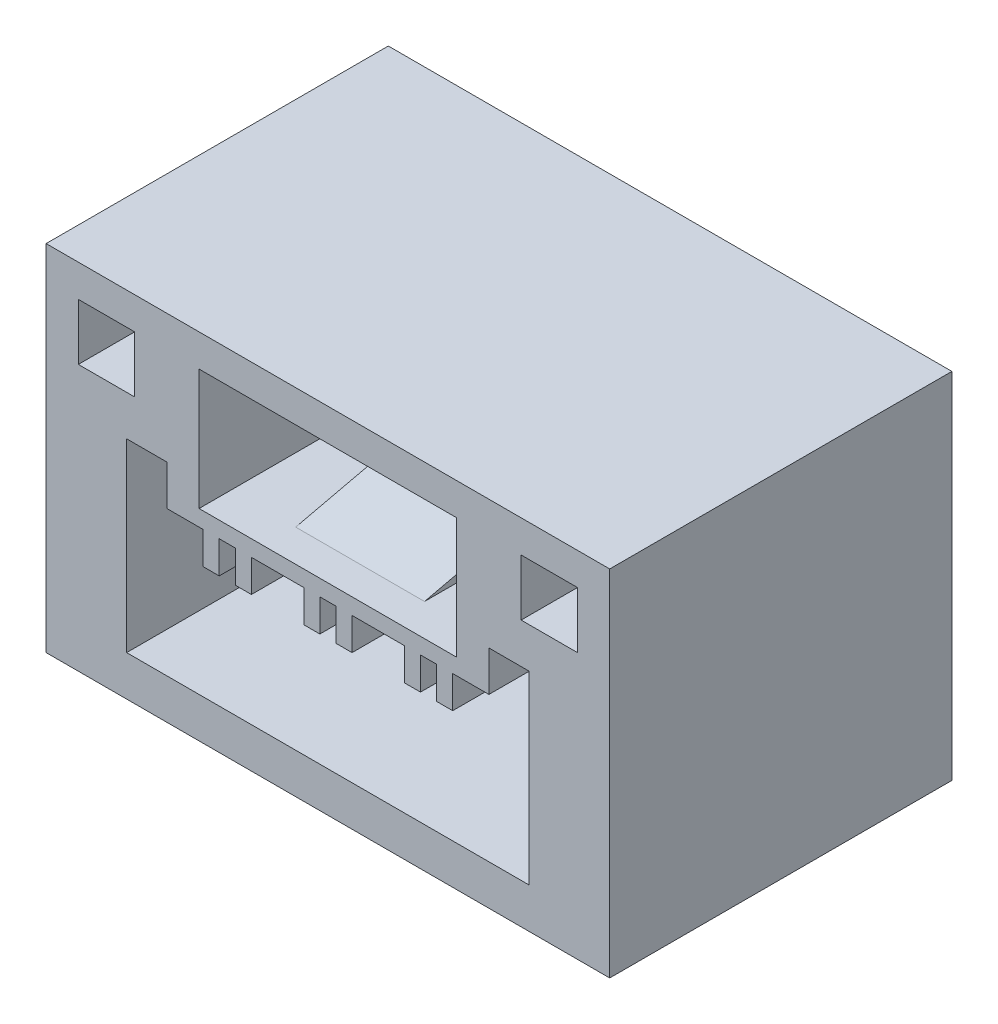
from build123d import *

# Parameters (mm, degrees)
SKETCH1_W                = 7
SKETCH1_H                = 4.4
SKETCH1_W_2              = 0.7
SKETCH1_H_2              = 0.7
SKETCH1_W_3              = 3.2
SKETCH1_H_3              = 1.5
BOSS_EXTRUDE1_DEPTH      = 4.25
SKETCH1_2_W              = 0.7
SKETCH1_2_H              = 0.7
BOSS_EXTRUDE2_DEPTH      = 1
BOSS_EXTRUDE3_START      = 4.25
SKETCH3_W                = 0.2
SKETCH3_H                = 0.4
BOSS_EXTRUDE3_DEPTH      = 3.25
LPATTERN1_COUNT          = 3
LPATTERN1_PITCH          = 1.25
BOSS_EXTRUDE4_DEPTH      = 0.8
BOSS_EXTRUDE4_DEPTH_BACK = 0.8


with BuildPart() as part:
    # Sketch1 → Boss-Extrude1 (new body)
    with BuildSketch(Plane.XY):
        Rectangle(SKETCH1_W, SKETCH1_H)
        Polygon((-2.5, 0.6), (-2.5, -1.7), (2.5, -1.7), (2.5, 0.6), (2, 0.6), (2, 0.1), (-2, 0.1), (-2, 0.6), align=None, mode=Mode.SUBTRACT)
        with Locations((-2.75, 1.45)):
            Rectangle(SKETCH1_W_2, SKETCH1_H_2, mode=Mode.SUBTRACT)
        with Locations((2.75, 1.45)):
            Rectangle(SKETCH1_W_2, SKETCH1_H_2, mode=Mode.SUBTRACT)
        with Locations((0, 1.05)):
            Rectangle(SKETCH1_W_3, SKETCH1_H_3, mode=Mode.SUBTRACT)
    extrude(amount=BOSS_EXTRUDE1_DEPTH)

    # Sketch1_2 → Boss-Extrude2 (add)
    with BuildSketch(Plane.XY):
        with Locations((2.75, 1.45)):
            Rectangle(SKETCH1_2_W, SKETCH1_2_H)
        Polygon((-2, 0.1), (-2, 0.6), (-2.5, 0.6), (-2.5, -1.7), (2.5, -1.7), (2.5, 0.6), (2, 0.6), (2, 0.1), align=None)
        with Locations((-2.75, 1.45)):
            Rectangle(SKETCH1_2_W, SKETCH1_2_H)
    extrude(amount=BOSS_EXTRUDE2_DEPTH)

    # Sketch3 → Boss-Extrude3 (add)
    with BuildSketch(Plane.XY.offset(BOSS_EXTRUDE3_START)):
        with Locations((1.05, -0.1)):
            Rectangle(SKETCH3_W, SKETCH3_H)
        with Locations((1.45, -0.1)):
            Rectangle(SKETCH3_W, SKETCH3_H)
    boss_extrude3 = extrude(amount=-BOSS_EXTRUDE3_DEPTH)

    # LPattern1: Boss-Extrude3 ×3
    with Locations(*[(-i * LPATTERN1_PITCH, 0, 0) for i in range(1, LPATTERN1_COUNT)]):
        add(boss_extrude3)

    # Sketch4 → Boss-Extrude4 (add, two sides)
    with BuildSketch(Plane(origin=(0, 0, 0), x_dir=(0, 0, -1), z_dir=(1, 0, 0))) as boss_extrude4_sk:
        Polygon((-2.125, 0.7), (-3.85, 0.3), (-2.125, 0.3), align=None)
    extrude(amount=BOSS_EXTRUDE4_DEPTH)
    extrude(boss_extrude4_sk.sketch, amount=-BOSS_EXTRUDE4_DEPTH_BACK)


solid = part.part
